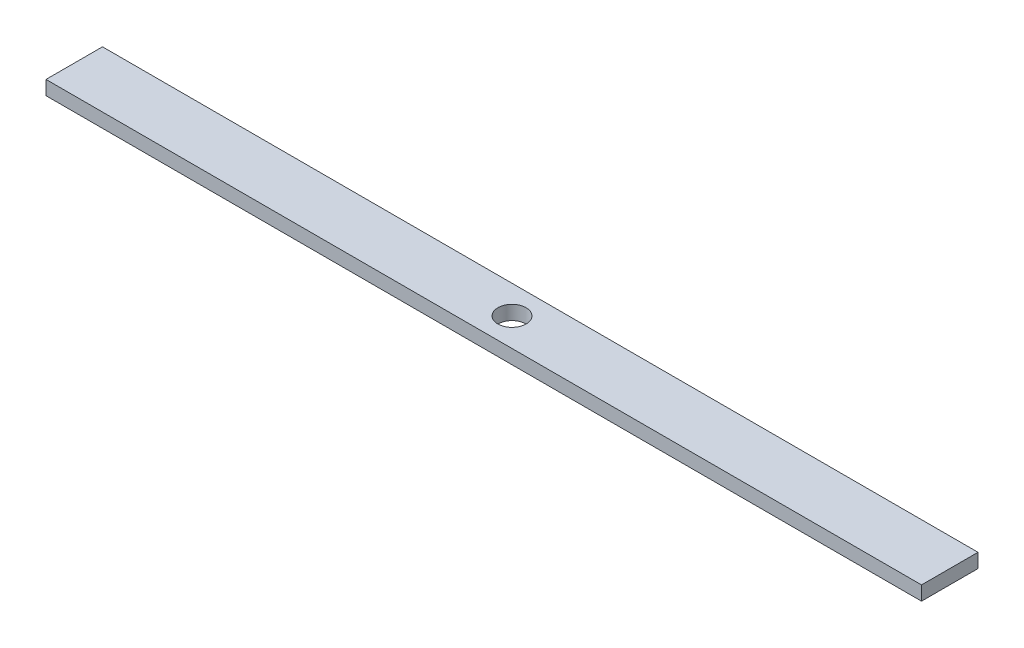
from build123d import *

# Parameters (mm, degrees)
SKETCH2_W           = 393.7
SKETCH2_H           = 25.4
SKETCH2_R           = 6.35
BOSS_EXTRUDE1_DEPTH = 6.35


with BuildPart() as part:
    # Sketch2 → Boss-Extrude1 (new body)
    with BuildSketch(Plane(origin=(0, 0, 0), x_dir=(1, 0, 0), z_dir=(0, 1, 0))):
        Rectangle(SKETCH2_W, SKETCH2_H)
        Circle(SKETCH2_R, mode=Mode.SUBTRACT)
    extrude(amount=BOSS_EXTRUDE1_DEPTH)


solid = part.part
